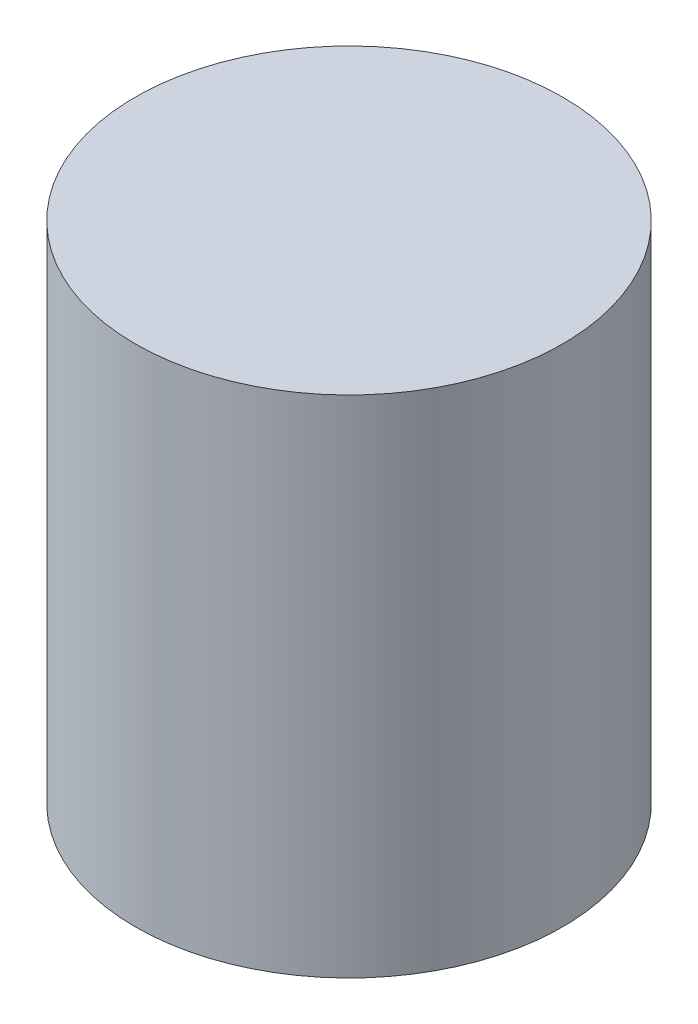
from build123d import *

# Parameters (mm, degrees)
SKETCH1_R           = 12.7
BOSS_EXTRUDE1_DEPTH = 30


with BuildPart() as part:
    # Sketch1 → Boss-Extrude1 (new body)
    with BuildSketch(Plane(origin=(0, 0, 0), x_dir=(1, 0, 0), z_dir=(0, 1, 0))):
        Circle(SKETCH1_R)
    extrude(amount=BOSS_EXTRUDE1_DEPTH)


solid = part.part
